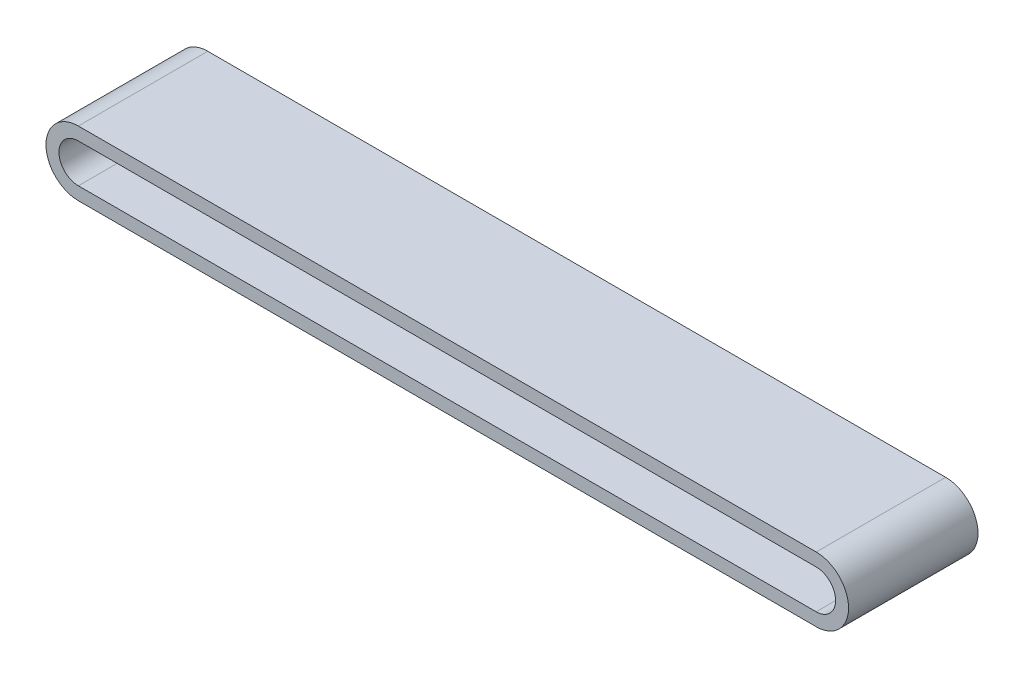
from build123d import *

# Parameters (mm, degrees)
EXTRUDE_THIN1_START = 10
EXTRUDE_THIN1_DEPTH = 100


with BuildPart() as part:
    # Sketch1 → Extrude-Thin1 (new body)
    with BuildSketch(Plane.XY.offset(EXTRUDE_THIN1_START)):
        with BuildLine():
            Line((264.897959184, -25), (-305.102040816, -25))
            ThreePointArc((-305.102040816, -25), (-330.102040816, 0), (-305.102040816, 25))
            Line((-305.102040816, 25), (264.897959184, 25))
            ThreePointArc((264.897959184, 25), (289.897959184, 0), (264.897959184, -25))
        make_face()
        with BuildLine():
            Line((264.897959184, -15), (-305.102040816, -15))
            ThreePointArc((-305.102040816, -15), (-320.102040816, 0), (-305.102040816, 15))
            Line((-305.102040816, 15), (264.897959184, 15))
            ThreePointArc((264.897959184, 15), (279.897959184, 0), (264.897959184, -15))
        make_face(mode=Mode.SUBTRACT)
    extrude(amount=EXTRUDE_THIN1_DEPTH)


solid = part.part
